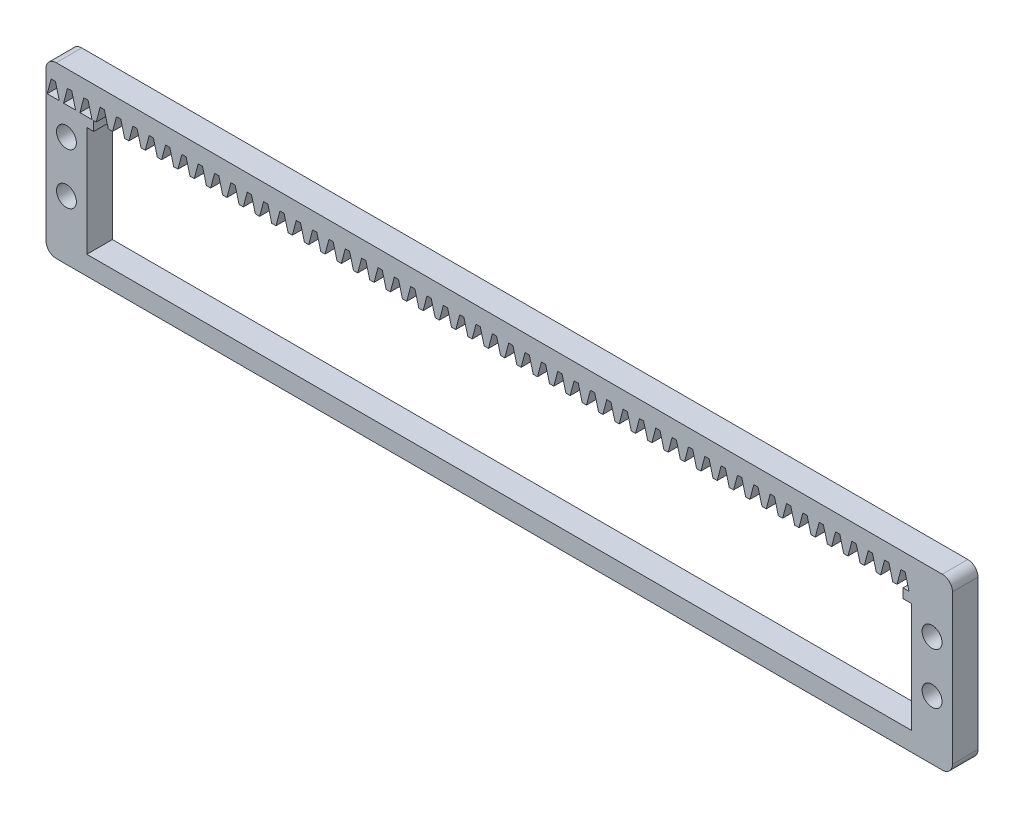
from build123d import *

# Parameters (mm, degrees)
BOSS_EXTRUDE1_DEPTH = 5
SKETCH2_W           = 161.5
SKETCH2_H           = 21.5
CUT_EXTRUDE1_DEPTH  = 6
SKETCH3_W           = 158.47
SKETCH3_H           = 1.85
CUT_EXTRUDE2_DEPTH  = 6
CUT_EXTRUDE4_DEPTH  = 6
LPATTERN1_COUNT     = 55
LPATTERN1_PITCH     = 3.2
SKETCH5_R           = 1.95
CUT_EXTRUDE5_DEPTH  = 10


with BuildPart() as part:
    # Sketch1 → Boss-Extrude1 (new body)
    with BuildSketch(Plane.XY):
        with BuildLine():
            Line((2, 0), (175.5, 0))
            ThreePointArc((175.5, 0), (176.914213562, -0.585786438), (177.5, -2))
            Line((177.5, -2), (177.5, -31.22))
            ThreePointArc((177.5, -31.22), (176.914213562, -32.634213562), (175.5, -33.22))
            Line((175.5, -33.22), (2, -33.22))
            ThreePointArc((2, -33.22), (0.585786438, -32.634213562), (0, -31.22))
            Line((0, -31.22), (0, -2))
            ThreePointArc((0, -2), (0.585786438, -0.585786438), (2, 0))
        make_face()
    extrude(amount=BOSS_EXTRUDE1_DEPTH)

    # Sketch2 → Cut-Extrude1 (cut, through all)
    with BuildSketch(Plane.XY.offset(5)):
        with Locations((88.75, -18.75)):
            Rectangle(SKETCH2_W, SKETCH2_H)
    extrude(amount=-CUT_EXTRUDE1_DEPTH, mode=Mode.SUBTRACT)

    # Sketch3 → Cut-Extrude2 (cut, through all)
    with BuildSketch(Plane.XY.offset(5)):
        with Locations((88.585, -7.075)):
            Rectangle(SKETCH3_W, SKETCH3_H)
    extrude(amount=-CUT_EXTRUDE2_DEPTH, mode=Mode.SUBTRACT)

    # Sketch4 → Cut-Extrude4 (cut, through all)
    with BuildSketch(Plane.XY.offset(5)):
        Polygon((168.235, -3.249176841), (169, -6.15), (166.64, -6.15), (167.405, -3.249176841), align=None)
    cut_extrude4 = extrude(amount=-CUT_EXTRUDE4_DEPTH, mode=Mode.SUBTRACT)

    # LPattern1: Cut-Extrude4 ×55
    with Locations(*[(-i * LPATTERN1_PITCH, 0, 0) for i in range(1, LPATTERN1_COUNT)]):
        add(cut_extrude4, mode=Mode.SUBTRACT)

    # Sketch5 → Cut-Extrude5 (cut)
    with BuildSketch(Plane.XY.offset(5)):
        with Locations((4, -11.61)):
            Circle(SKETCH5_R)
        with Locations((4, -21.61)):
            Circle(SKETCH5_R)
        with Locations((173.5, -11.61)):
            Circle(SKETCH5_R)
        with Locations((173.5, -21.61)):
            Circle(SKETCH5_R)
    extrude(amount=-CUT_EXTRUDE5_DEPTH, mode=Mode.SUBTRACT)


solid = part.part
